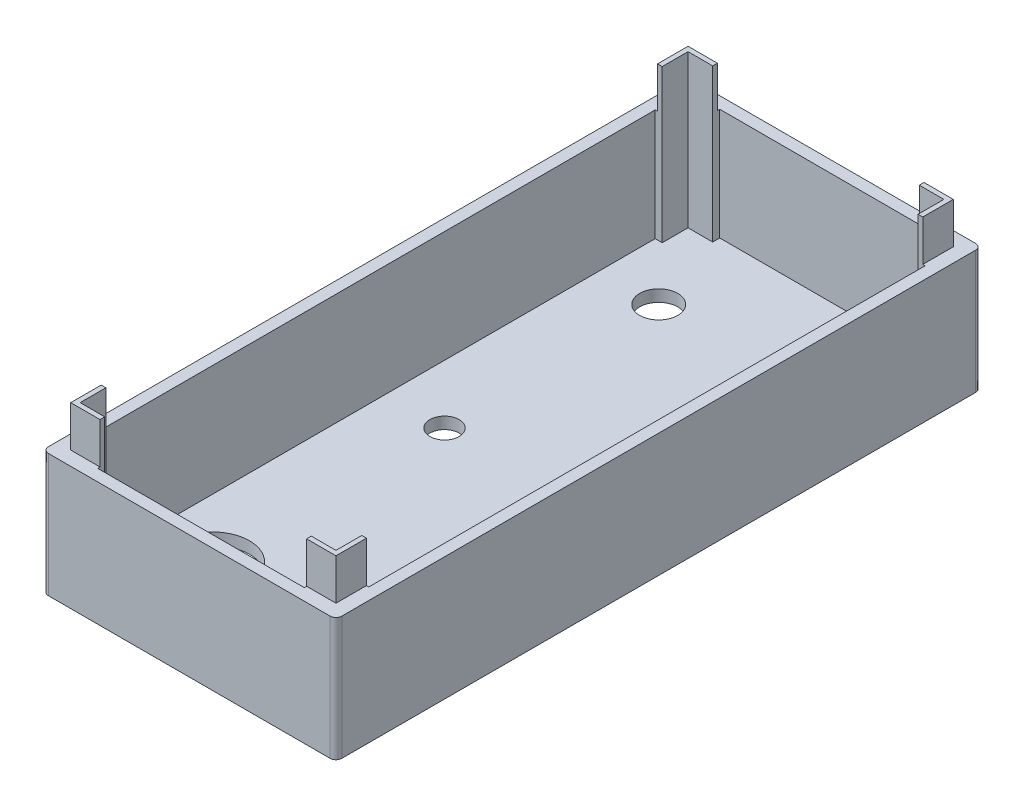
from build123d import *

# Parameters (mm, degrees)
SKETCH1_W                = 50
SKETCH1_H                = 110
BOSS_EXTRUDE1_DEPTH      = 2
SKETCH2_W                = 50
SKETCH2_H                = 110
SKETCH2_W_2              = 46
SKETCH2_H_2              = 106
BOSS_EXTRUDE3_DEPTH      = 11
SKETCH3_R                = 1.2
BOSS_EXTRUDE4_DEPTH      = 11
SKETCH4_W                = 52
SKETCH4_H                = 112
SKETCH4_W_2              = 50
SKETCH4_H_2              = 110
EXTRUDE_THIN1_DEPTH      = 13
FILLET2_R                = 2
EXTRUDE_THIN3_DEPTH      = 3
SKETCH6_R                = 1.8
BOSS_EXTRUDE5_DEPTH      = 2.8
SKETCH8_W                = 8
SKETCH8_H                = 3.6
CUT_EXTRUDE2_DEPTH       = 12.8
SKETCH11_W               = 13.1
SKETCH11_H               = 5.8
CUT_EXTRUDE5_DEPTH       = 3
SKETCH12_W               = 70
SKETCH12_H               = 9.973266712
CUT_EXTRUDE6_DEPTH       = 130
SKETCH13_W               = 46
SKETCH13_H               = 106
CUT_EXTRUDE7_DEPTH       = 130
SKETCH15_W               = 46
SKETCH15_H               = 106
BOSS_EXTRUDE6_DEPTH      = 60
SKETCH16_W               = 71.739839436
SKETCH16_H               = 55.166081701
CUT_EXTRUDE8_DEPTH       = 130
SKETCH17_W               = 110.8
SKETCH17_H               = 170.8
SKETCH17_W_2             = 48.4
SKETCH17_H_2             = 108.4
CUT_EXTRUDE_THIN1_DEPTH  = 3
SKETCH18_W               = 3
SKETCH18_H               = 13.1
BOSS_EXTRUDE7_DEPTH      = 7
SKETCH19_W               = 3
SKETCH19_H               = 8
BOSS_EXTRUDE8_DEPTH      = 4.5
SKETCH20_R               = 6
SKETCH20_R_2             = 3
CUT_EXTRUDE9_DEPTH       = 4.5
CUT_EXTRUDE_THIN3_DEPTH  = 80
SKETCH24_W               = 48.4
SKETCH24_H               = 3
CUT_EXTRUDE10_DEPTH      = 140
SKETCH26_W               = 46
SKETCH26_H               = 106
SKETCH26_W_2             = 43.6
SKETCH26_H_2             = 103.6
EXTRUDE_THIN5_DEPTH      = 26
SKETCH27_W               = 47.6
SKETCH27_H               = 107.6
SKETCH27_W_2             = 45.2
SKETCH27_H_2             = 105.2
CUT_EXTRUDE_THIN4_DEPTH  = 7
SKETCH28_W               = 94.8
SKETCH28_H               = 7
CUT_EXTRUDE11_DEPTH      = 7
CUT_EXTRUDE11_DEPTH_BACK = 87
SKETCH29_W               = 35.2
SKETCH29_H               = 7
CUT_EXTRUDE12_DEPTH      = 87
CUT_EXTRUDE12_DEPTH_BACK = 137
SKETCH30_W               = 1.2
SKETCH30_H               = 94.8
SKETCH30_W_2             = 35.2
SKETCH30_H_2             = 1.2
CUT_EXTRUDE13_DEPTH      = 19
SKETCH31_R               = 6.25
CUT_EXTRUDE14_DEPTH      = 10
CUT_EXTRUDE14_DEPTH_BACK = 10
SKETCH32_R               = 3.25
CUT_EXTRUDE17_DEPTH      = 10
SKETCH35_R               = 2.5
CUT_EXTRUDE18_DEPTH      = 10
CUT_EXTRUDE18_DEPTH_BACK = 10


with BuildPart() as part:
    # Sketch1 → Boss-Extrude1 (new body)
    with BuildSketch(Plane(origin=(0, 0, 0), x_dir=(1, 0, 0), z_dir=(0, 1, 0))):
        with Locations((-52.022587269, -1.919917864)):
            Rectangle(SKETCH1_W, SKETCH1_H)
    extrude(amount=BOSS_EXTRUDE1_DEPTH)

    # Sketch2 → Boss-Extrude3 (add)
    with BuildSketch(Plane(origin=(0, 2, 0), x_dir=(1, 0, 0), z_dir=(0, 1, 0))):
        with Locations((-52.022587269, -1.919917864)):
            Rectangle(SKETCH2_W, SKETCH2_H)
        with Locations((-52.022587269, -1.919917864)):
            Rectangle(SKETCH2_W_2, SKETCH2_H_2, mode=Mode.SUBTRACT)
    extrude(amount=BOSS_EXTRUDE3_DEPTH)

    # Sketch3 → Boss-Extrude4 (add)
    with BuildSketch(Plane(origin=(0, 2, 0), x_dir=(1, 0, 0), z_dir=(0, 1, 0))):
        with Locations((-31.022587269, 42.380082136)):
            Circle(SKETCH3_R)
        with Locations((-31.022587269, -52.919917864)):
            Circle(SKETCH3_R)
        with Locations((-56.322587269, 42.380082136)):
            Circle(SKETCH3_R)
        with Locations((-56.322587269, -52.919917864)):
            Circle(SKETCH3_R)
    extrude(amount=BOSS_EXTRUDE4_DEPTH)

    # Sketch4 → Extrude-Thin1 (add)
    with BuildSketch(Plane(origin=(0, 13, 0), x_dir=(1, 0, 0), z_dir=(0, 1, 0))):
        with Locations((-52.022587269, -1.919917864)):
            Rectangle(SKETCH4_W, SKETCH4_H)
        with Locations((-52.022587269, -1.919917864)):
            Rectangle(SKETCH4_W_2, SKETCH4_H_2, mode=Mode.SUBTRACT)
    extrude(amount=-EXTRUDE_THIN1_DEPTH)

    # Fillet2
    fillet2_edges = [part.edges().sort_by_distance(p)[0] for p in [
        (-26.022587269, 6.5, -54.080082136),
        (-26.022587269, 6.5, 57.919917864),
        (-78.022587269, 6.5, 57.919917864),
        (-78.022587269, 6.5, -54.080082136),
    ]]
    fillet(fillet2_edges, radius=FILLET2_R)

    # Sketch5 → Extrude-Thin3 (add)
    with BuildSketch(Plane(origin=(0, 13, 0), x_dir=(1, 0, 0), z_dir=(0, 1, 0))):
        with BuildLine():
            Line((-28.022587269, 54.080082136), (-76.022587269, 54.080082136))
            ThreePointArc((-76.022587269, 54.080082136), (-77.436800831, 53.494295698), (-78.022587269, 52.080082136))
            Line((-78.022587269, 52.080082136), (-78.022587269, -55.919917864))
            ThreePointArc((-78.022587269, -55.919917864), (-77.436800831, -57.334131427), (-76.022587269, -57.919917864))
            Line((-76.022587269, -57.919917864), (-28.022587269, -57.919917864))
            ThreePointArc((-28.022587269, -57.919917864), (-26.608373707, -57.334131427), (-26.022587269, -55.919917864))
            Line((-26.022587269, -55.919917864), (-26.022587269, 52.080082136))
            ThreePointArc((-26.022587269, 52.080082136), (-26.608373707, 53.494295698), (-28.022587269, 54.080082136))
        make_face()
        with BuildLine():
            Line((-28.022587269, 52.880082136), (-76.022587269, 52.880082136))
            ThreePointArc((-76.022587269, 52.880082136), (-76.588272694, 52.64576756), (-76.822587269, 52.080082136))
            Line((-76.822587269, 52.080082136), (-76.822587269, -55.919917864))
            ThreePointArc((-76.822587269, -55.919917864), (-76.588272694, -56.485603289), (-76.022587269, -56.719917864))
            Line((-76.022587269, -56.719917864), (-28.022587269, -56.719917864))
            ThreePointArc((-28.022587269, -56.719917864), (-27.456901844, -56.485603289), (-27.222587269, -55.919917864))
            Line((-27.222587269, -55.919917864), (-27.222587269, 52.080082136))
            ThreePointArc((-27.222587269, 52.080082136), (-27.456901844, 52.64576756), (-28.022587269, 52.880082136))
        make_face(mode=Mode.SUBTRACT)
    extrude(amount=EXTRUDE_THIN3_DEPTH)

    # Sketch6 → Boss-Extrude5 (add)
    with BuildSketch(Plane(origin=(0, 2, 0), x_dir=(1, 0, 0), z_dir=(0, 1, 0))):
        with Locations((-56.322587269, -52.919917864)):
            Circle(SKETCH6_R)
        with Locations((-31.022587269, -52.919917864)):
            Circle(SKETCH6_R)
        with Locations((-56.322587269, 42.380082136)):
            Circle(SKETCH6_R)
        with Locations((-31.022587269, 42.380082136)):
            Circle(SKETCH6_R)
    extrude(amount=BOSS_EXTRUDE5_DEPTH)

    # Sketch8 → Cut-Extrude2 (cut)
    with BuildSketch(Plane(origin=(-26.022587269, 0, 0), x_dir=(0, 0, -1), z_dir=(1, 0, 0))):
        with Locations((-44.619917864, 3.8)):
            Rectangle(SKETCH8_W, SKETCH8_H)
    extrude(amount=-CUT_EXTRUDE2_DEPTH, mode=Mode.SUBTRACT)

    # Sketch11 → Cut-Extrude5 (cut)
    with BuildSketch(Plane.ZY.offset(78.022587269)):
        with Locations((-43.530082136, 4.9)):
            Rectangle(SKETCH11_W, SKETCH11_H)
    extrude(amount=-CUT_EXTRUDE5_DEPTH, mode=Mode.SUBTRACT)

    # Sketch12 → Cut-Extrude6 (cut)
    with BuildSketch(Plane.XY.offset(57.919917864)):
        with Locations((-53.022587269, 15.377484965)):
            Rectangle(SKETCH12_W, SKETCH12_H)
    extrude(amount=-CUT_EXTRUDE6_DEPTH, mode=Mode.SUBTRACT)

    # Sketch13 → Cut-Extrude7 (cut)
    with BuildSketch(Plane(origin=(0, 2, 0), x_dir=(1, 0, 0), z_dir=(0, 1, 0))):
        with Locations((-52.022587269, -1.919917864)):
            Rectangle(SKETCH13_W, SKETCH13_H)
    extrude(amount=CUT_EXTRUDE7_DEPTH, mode=Mode.SUBTRACT)

    # Sketch15 → Boss-Extrude6 (add)
    with BuildSketch(Plane(origin=(0, 10.390851609, 0), x_dir=(1, 0, 0), z_dir=(0, 1, 0))):
        with BuildLine():
            Line((-76.022587269, -57.919917864), (-28.022587269, -57.919917864))
            ThreePointArc((-28.022587269, -57.919917864), (-26.608373707, -57.334131427), (-26.022587269, -55.919917864))
            Line((-26.022587269, -55.919917864), (-26.022587269, 52.080082136))
            ThreePointArc((-26.022587269, 52.080082136), (-26.608373707, 53.494295698), (-28.022587269, 54.080082136))
            Line((-28.022587269, 54.080082136), (-76.022587269, 54.080082136))
            ThreePointArc((-76.022587269, 54.080082136), (-77.436800831, 53.494295698), (-78.022587269, 52.080082136))
            Line((-78.022587269, 52.080082136), (-78.022587269, -55.919917864))
            ThreePointArc((-78.022587269, -55.919917864), (-77.436800831, -57.334131427), (-76.022587269, -57.919917864))
        make_face()
        with Locations((-52.022587269, -1.919917864)):
            Rectangle(SKETCH15_W, SKETCH15_H, mode=Mode.SUBTRACT)
    extrude(amount=BOSS_EXTRUDE6_DEPTH)

    # Sketch16 → Cut-Extrude8 (cut)
    with BuildSketch(Plane.XY.offset(57.919917864)):
        with Locations((-48.522353235, 51.583040851)):
            Rectangle(SKETCH16_W, SKETCH16_H)
    extrude(amount=-CUT_EXTRUDE8_DEPTH, mode=Mode.SUBTRACT)

    # Sketch17 → Cut-Extrude-Thin1 (cut)
    with BuildSketch(Plane(origin=(0, 24, 0), x_dir=(1, 0, 0), z_dir=(0, 1, 0))):
        with Locations((-52.022587269, -1.919917864)):
            Rectangle(SKETCH17_W, SKETCH17_H)
        with Locations((-52.022587269, -1.919917864)):
            Rectangle(SKETCH17_W_2, SKETCH17_H_2, mode=Mode.SUBTRACT)
    extrude(amount=-CUT_EXTRUDE_THIN1_DEPTH, mode=Mode.SUBTRACT)

    # Sketch18 → Boss-Extrude7 (add)
    with BuildSketch(Plane.XZ.offset(-7.8)):
        with Locations((-76.522587269, -43.530082136)):
            Rectangle(SKETCH18_W, SKETCH18_H)
    extrude(amount=BOSS_EXTRUDE7_DEPTH)

    # Sketch19 → Boss-Extrude8 (add)
    with BuildSketch(Plane.XZ.offset(-5.6)):
        with Locations((-27.522587269, 44.619917864)):
            Rectangle(SKETCH19_W, SKETCH19_H)
    extrude(amount=BOSS_EXTRUDE8_DEPTH)

    # Sketch20 → Cut-Extrude9 (cut)
    with BuildSketch(Plane(origin=(0, 2, 0), x_dir=(1, 0, 0), z_dir=(0, 1, 0))):
        with Locations((-65.022587269, -39.919917864)):
            Circle(SKETCH20_R)
        with Locations((-65.022587269, 36.080082136)):
            Circle(SKETCH20_R_2)
    extrude(amount=-CUT_EXTRUDE9_DEPTH, mode=Mode.SUBTRACT)

    # Sketch23 → Cut-Extrude-Thin3 (cut)
    with BuildSketch(Plane(origin=(0, 21, 0), x_dir=(1, 0, 0), z_dir=(0, 1, 0))):
        with BuildLine():
            Line((-87.022587269, 52.080082136), (-87.022587269, -55.919917864))
            ThreePointArc((-87.022587269, -55.919917864), (-83.800761862, -63.698092458), (-76.022587269, -66.919917864))
            Line((-76.022587269, -66.919917864), (-28.022587269, -66.919917864))
            ThreePointArc((-28.022587269, -66.919917864), (-20.244412676, -63.698092458), (-17.022587269, -55.919917864))
            Line((-17.022587269, -55.919917864), (-17.022587269, 52.080082136))
            ThreePointArc((-17.022587269, 52.080082136), (-20.244412676, 59.858256729), (-28.022587269, 63.080082136))
            Line((-28.022587269, 63.080082136), (-76.022587269, 63.080082136))
            ThreePointArc((-76.022587269, 63.080082136), (-83.800761862, 59.858256729), (-87.022587269, 52.080082136))
        make_face()
        with BuildLine():
            Line((-77.022587269, 52.080082136), (-77.022587269, -55.919917864))
            ThreePointArc((-77.022587269, -55.919917864), (-76.72969405, -56.627024646), (-76.022587269, -56.919917864))
            Line((-76.022587269, -56.919917864), (-28.022587269, -56.919917864))
            ThreePointArc((-28.022587269, -56.919917864), (-27.315480488, -56.627024646), (-27.022587269, -55.919917864))
            Line((-27.022587269, -55.919917864), (-27.022587269, 52.080082136))
            ThreePointArc((-27.022587269, 52.080082136), (-27.315480488, 52.787188917), (-28.022587269, 53.080082136))
            Line((-28.022587269, 53.080082136), (-76.022587269, 53.080082136))
            ThreePointArc((-76.022587269, 53.080082136), (-76.72969405, 52.787188917), (-77.022587269, 52.080082136))
        make_face(mode=Mode.SUBTRACT)
    extrude(amount=-CUT_EXTRUDE_THIN3_DEPTH, mode=Mode.SUBTRACT)

    # Sketch24 → Cut-Extrude10 (cut)
    with BuildSketch(Plane.XY.offset(56.119917864)):
        with Locations((-52.022587269, 22.5)):
            Rectangle(SKETCH24_W, SKETCH24_H)
    extrude(amount=-CUT_EXTRUDE10_DEPTH, mode=Mode.SUBTRACT)

    # Sketch26 → Extrude-Thin5 (add)
    with BuildSketch(Plane(origin=(0, 2, 0), x_dir=(1, 0, 0), z_dir=(0, 1, 0))):
        with Locations((-52.022587269, -1.919917864)):
            Rectangle(SKETCH26_W, SKETCH26_H)
        with Locations((-52.022587269, -1.919917864)):
            Rectangle(SKETCH26_W_2, SKETCH26_H_2, mode=Mode.SUBTRACT)
    extrude(amount=EXTRUDE_THIN5_DEPTH)

    # Sketch27 → Cut-Extrude-Thin4 (cut)
    with BuildSketch(Plane(origin=(0, 28, 0), x_dir=(1, 0, 0), z_dir=(0, 1, 0))):
        with Locations((-52.022587269, -1.919917864)):
            Rectangle(SKETCH27_W, SKETCH27_H)
        with Locations((-52.022587269, -1.919917864)):
            Rectangle(SKETCH27_W_2, SKETCH27_H_2, mode=Mode.SUBTRACT)
    extrude(amount=-CUT_EXTRUDE_THIN4_DEPTH, mode=Mode.SUBTRACT)

    # Sketch28 → Cut-Extrude11 (cut, two sides)
    with BuildSketch(Plane(origin=(-29.422587269, 0, 0), x_dir=(0, 0, -1), z_dir=(1, 0, 0))) as cut_extrude11_sk:
        with Locations((-1.919917864, 24.5)):
            Rectangle(SKETCH28_W, SKETCH28_H)
    extrude(amount=CUT_EXTRUDE11_DEPTH, mode=Mode.SUBTRACT)
    extrude(cut_extrude11_sk.sketch, amount=-CUT_EXTRUDE11_DEPTH_BACK, mode=Mode.SUBTRACT)

    # Sketch29 → Cut-Extrude12 (cut, two sides)
    with BuildSketch(Plane.XY.offset(54.519917864)) as cut_extrude12_sk:
        with Locations((-52.022587269, 24.5)):
            Rectangle(SKETCH29_W, SKETCH29_H)
    extrude(amount=CUT_EXTRUDE12_DEPTH, mode=Mode.SUBTRACT)
    extrude(cut_extrude12_sk.sketch, amount=-CUT_EXTRUDE12_DEPTH_BACK, mode=Mode.SUBTRACT)

    # Sketch30 → Cut-Extrude13 (cut)
    with BuildSketch(Plane(origin=(0, 21, 0), x_dir=(1, 0, 0), z_dir=(0, 1, 0))):
        with Locations((-74.422587269, -1.919917864)):
            Rectangle(SKETCH30_W, SKETCH30_H)
        with Locations((-52.022587269, -54.319917864)):
            Rectangle(SKETCH30_W_2, SKETCH30_H_2)
        with Locations((-29.622587269, -1.919917864)):
            Rectangle(SKETCH30_W, SKETCH30_H)
        with Locations((-52.022587269, 50.480082136)):
            Rectangle(SKETCH30_W_2, SKETCH30_H_2)
    extrude(amount=-CUT_EXTRUDE13_DEPTH, mode=Mode.SUBTRACT)

    # Sketch31 → Cut-Extrude14 (cut, two sides)
    with BuildSketch(Plane(origin=(0, 2, 0), x_dir=(1, 0, 0), z_dir=(0, 1, 0))) as cut_extrude14_sk:
        with Locations((-65.022587269, -39.919917864)):
            Circle(SKETCH31_R)
    extrude(amount=CUT_EXTRUDE14_DEPTH, mode=Mode.SUBTRACT)
    extrude(cut_extrude14_sk.sketch, amount=-CUT_EXTRUDE14_DEPTH_BACK, mode=Mode.SUBTRACT)

    # Sketch32 → Cut-Extrude17 (cut)
    with BuildSketch(Plane(origin=(0, 2, 0), x_dir=(1, 0, 0), z_dir=(0, 1, 0))):
        with Locations((-65.022587269, 36.080082136)):
            Circle(SKETCH32_R)
    extrude(amount=-CUT_EXTRUDE17_DEPTH, mode=Mode.SUBTRACT)

    # Sketch35 → Cut-Extrude18 (cut, two sides)
    with BuildSketch(Plane(origin=(0, 2, 0), x_dir=(1, 0, 0), z_dir=(0, 1, 0))) as cut_extrude18_sk:
        with Locations((-65.022587269, -0.419917864)):
            Circle(SKETCH35_R)
    extrude(amount=CUT_EXTRUDE18_DEPTH, mode=Mode.SUBTRACT)
    extrude(cut_extrude18_sk.sketch, amount=-CUT_EXTRUDE18_DEPTH_BACK, mode=Mode.SUBTRACT)


solid = part.part
